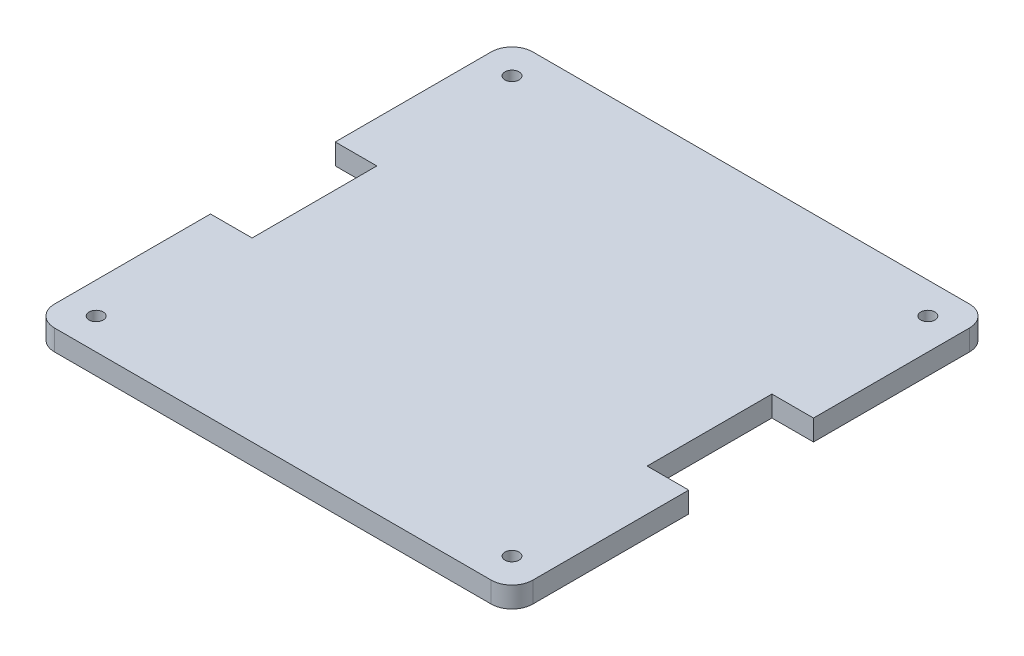
from build123d import *

# Parameters (mm, degrees)
SKETCH1_W           = 146.05
SKETCH1_H           = 146.05
BOSS_EXTRUDE1_DEPTH = 6.35
SKETCH2_R           = 2.15265
CUT_EXTRUDE1_DEPTH  = 6.35
FILLET1_R           = 6.35
SKETCH3_W           = 12.7
SKETCH3_H           = 38.1
CUT_EXTRUDE2_DEPTH  = 6.35


with BuildPart() as part:
    # Sketch1 → Boss-Extrude1 (new body)
    with BuildSketch(Plane(origin=(0, 0, 0), x_dir=(1, 0, 0), z_dir=(0, 1, 0))):
        Rectangle(SKETCH1_W, SKETCH1_H)
    extrude(amount=BOSS_EXTRUDE1_DEPTH)

    # Sketch2 → Cut-Extrude1 (cut)
    with BuildSketch(Plane(origin=(0, 6.35, 0), x_dir=(1, 0, 0), z_dir=(0, 1, 0))):
        with Locations((-63.5, 63.5)):
            Circle(SKETCH2_R)
        with Locations((63.5, 63.5)):
            Circle(SKETCH2_R)
        with Locations((63.5, -63.5)):
            Circle(SKETCH2_R)
        with Locations((-63.5, -63.5)):
            Circle(SKETCH2_R)
    extrude(amount=-CUT_EXTRUDE1_DEPTH, mode=Mode.SUBTRACT)

    # Fillet1
    fillet1_edges = [part.edges().sort_by_distance(p)[0] for p in [
        (73.025, 3.175, 73.025),
        (-73.025, 3.175, 73.025),
        (-73.025, 3.175, -73.025),
        (73.025, 3.175, -73.025),
    ]]
    fillet(fillet1_edges, radius=FILLET1_R)

    # Sketch3 → Cut-Extrude2 (cut)
    with BuildSketch(Plane(origin=(0, 6.35, 0), x_dir=(1, 0, 0), z_dir=(0, 1, 0))):
        with Locations((66.675, 0)):
            Rectangle(SKETCH3_W, SKETCH3_H)
    cut_extrude2 = extrude(amount=-CUT_EXTRUDE2_DEPTH, mode=Mode.SUBTRACT)

    # Mirror1: Cut-Extrude2 across plane
    add(cut_extrude2.mirror(Plane(origin=(0, 0, 0), x_dir=(0, 0, 1), z_dir=(1, 0, 0))), mode=Mode.SUBTRACT)


solid = part.part
